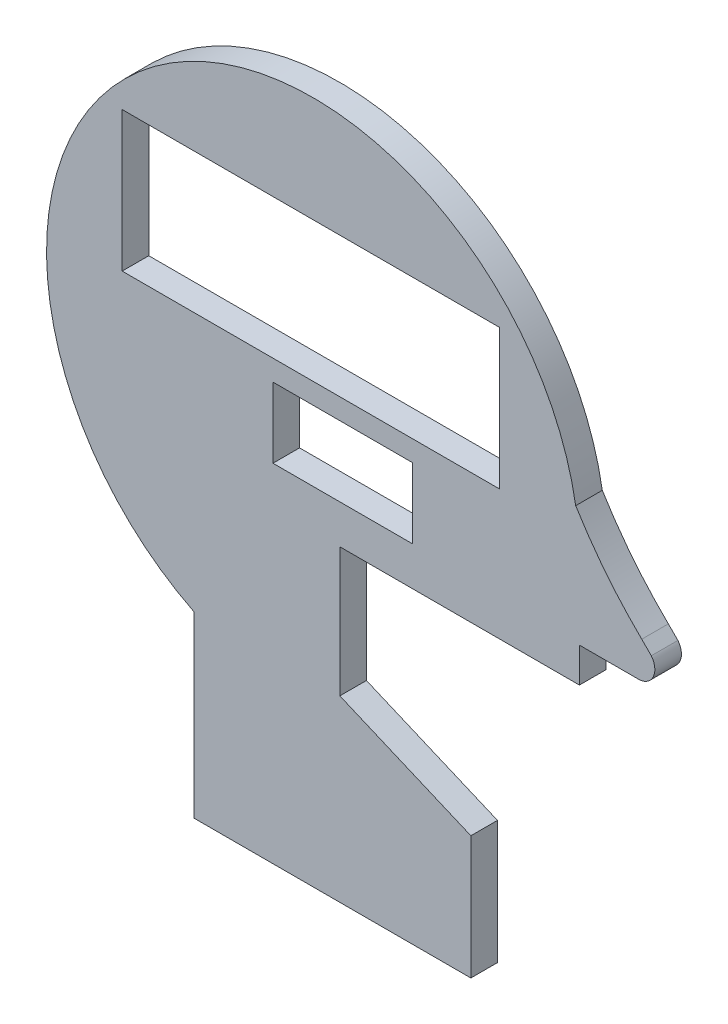
from build123d import *

# Parameters (mm, degrees)
BOSS_EXTRUDE3_DEPTH = 7.62
SKETCH6_W           = 108.110429846
SKETCH6_H           = 40.078189215
SKETCH6_W_2         = 39.947123602
SKETCH6_H_2         = 20.1313586
CUT_EXTRUDE5_DEPTH  = 7.62


with BuildPart() as part:
    # Sketch2 → Boss-Extrude3 (new body)
    with BuildSketch(Plane.XY):
        with BuildLine():
            Line((96.126803593, -12.916705994), (94.17394782, -10.963850221))
            add(Edge.make_bspline(
                [(75.252666665, 12.699131487), (83.268217656, -0.404579698), (94.17394782, -10.963850221)],
                knots=[0, 0, 0, 1, 1, 1], degree=2))
            ThreePointArc((75.252666665, 12.699131487), (-45.402140278, 61.342297308), (-34.129845534, -68.259691067))
            Line((-34.129845534, -68.259691067), (-34.129845534, -119.480702222))
            Line((-34.129845534, -119.480702222), (45.224618014, -119.480702222))
            Line((45.224618014, -119.480702222), (45.224618014, -84.189817543))
            Line((45.224618014, -84.189817543), (7.693042244, -68.259691067))
            Line((7.693042244, -68.259691067), (7.693042244, -31.273550257))
            Line((7.693042244, -31.273550257), (76.316654675, -31.273550257))
            Line((76.316654675, -31.273550257), (76.316654675, -21.354495246))
            Line((76.316654675, -21.354495246), (93.197519934, -21.354495246))
            ThreePointArc((93.197519934, -21.354495246), (97.451679759, -18.688706069), (96.907945902, -13.697848303))
            Line((96.907945902, -13.697848303), (96.126803593, -12.916705994))
        make_face()
    extrude(amount=BOSS_EXTRUDE3_DEPTH)

    # Sketch6 → Cut-Extrude5 (cut)
    with BuildSketch(Plane.XY.offset(7.62)):
        with Locations((-0.597955264, 25.976582243)):
            Rectangle(SKETCH6_W, SKETCH6_H)
        with Locations((8.508452954, -10.0656793)):
            Rectangle(SKETCH6_W_2, SKETCH6_H_2)
    extrude(amount=-CUT_EXTRUDE5_DEPTH, mode=Mode.SUBTRACT)


solid = part.part
